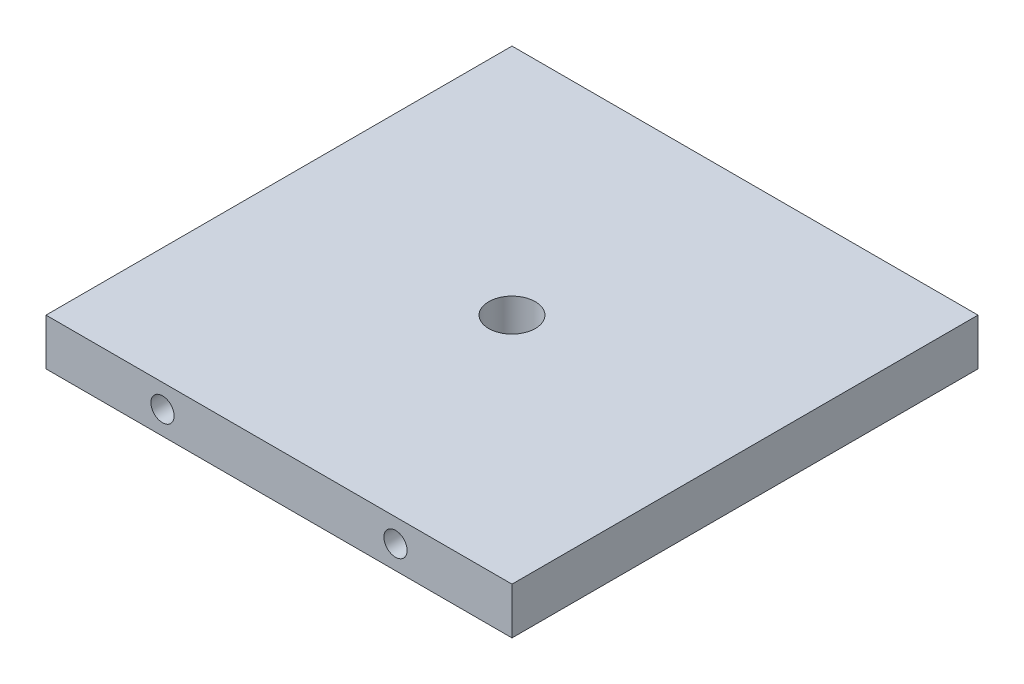
from build123d import *

# Parameters (mm, degrees)
SKETCH_1_W          = 100
SKETCH_1_H          = 100
EXTRUDE_1_DEPTH     = 10
SKETCH_2_R          = 2.5
CUT_EXTRUDE_1_DEPTH = 10
SKETCH_3_R          = 2.5
CUT_EXTRUDE_2_DEPTH = 10
SKETCH_4_R          = 5
CUT_EXTRUDE_3_DEPTH = 11


with BuildPart() as part:
    # Эскиз1 → Бобышка-Вытянуть1 (new body)
    with BuildSketch(Plane(origin=(0, 0, 0), x_dir=(1, 0, 0), z_dir=(0, 1, 0))):
        Rectangle(SKETCH_1_W, SKETCH_1_H)
    extrude(amount=EXTRUDE_1_DEPTH)

    # Эскиз2 → Вырез-Вытянуть1 (cut)
    with BuildSketch(Plane.XY.offset(50)):
        with Locations((-25, 5)):
            Circle(SKETCH_2_R)
        with Locations((25, 5)):
            Circle(SKETCH_2_R)
    extrude(amount=-CUT_EXTRUDE_1_DEPTH, mode=Mode.SUBTRACT)

    # Эскиз3 → Вырез-Вытянуть2 (cut)
    with BuildSketch(Plane(origin=(0, 0, -50), x_dir=(-1, 0, 0), z_dir=(0, 0, -1))):
        with Locations((-25, 5)):
            Circle(SKETCH_3_R)
        with Locations((25, 5)):
            Circle(SKETCH_3_R)
    extrude(amount=-CUT_EXTRUDE_2_DEPTH, mode=Mode.SUBTRACT)

    # Эскиз4 → Вырез-Вытянуть3 (cut, through all)
    with BuildSketch(Plane(origin=(0, 10, 0), x_dir=(1, 0, 0), z_dir=(0, 1, 0))):
        Circle(SKETCH_4_R)
    extrude(amount=-CUT_EXTRUDE_3_DEPTH, mode=Mode.SUBTRACT)


solid = part.part
